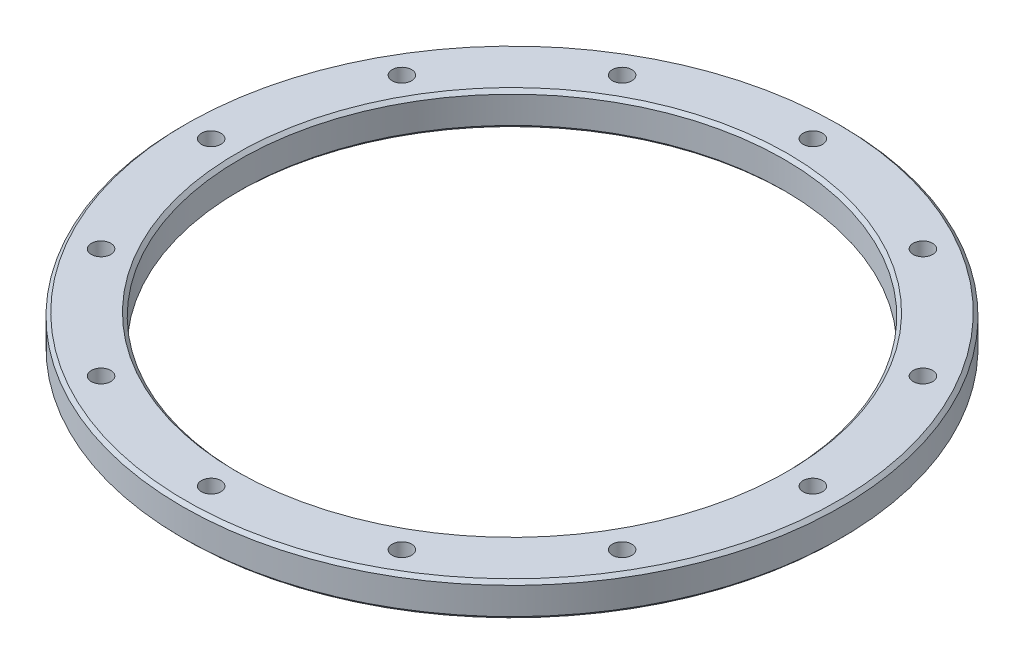
from build123d import *

# Parameters (mm, degrees)
SKETCH1_R           = 61.9125
SKETCH1_R_2         = 51.1175
BOSS_EXTRUDE1_DEPTH = 6.35
CHAMFER1_SIZE       = 0.635
CHAMFER2_SIZE       = 0.635
HOLE1_D             = 3.66
CIRPATTERN1_COUNT   = 12
CHAMFER3_SIZE       = 0.635
CHAMFER4_SIZE       = 0.635


with BuildPart() as part:
    # Sketch1 → Boss-Extrude1 (new body)
    with BuildSketch(Plane(origin=(0, 6.35, 0), x_dir=(1, 0, 0), z_dir=(0, 1, 0))):
        Circle(SKETCH1_R)
        Circle(SKETCH1_R_2, mode=Mode.SUBTRACT)
    extrude(amount=-BOSS_EXTRUDE1_DEPTH)

    # Chamfer1
    chamfer1_edges = [part.edges().sort_by_distance(p)[0] for p in [
        (-51.1175, 0, 0),
    ]]
    chamfer(chamfer1_edges, length=CHAMFER1_SIZE)

    # Chamfer2
    chamfer2_edges = [part.edges().sort_by_distance(p)[0] for p in [
        (-51.1175, 6.35, 0),
    ]]
    chamfer(chamfer2_edges, length=CHAMFER2_SIZE)

    # Hole1 (through all)
    with Locations(Plane(origin=(0, 0, 0), x_dir=(-1, 0, 0), z_dir=(0, -1, 0))):
        with Locations((28.2575, -48.943425695)):
            hole1 = Hole(HOLE1_D / 2)

    # CirPattern1: Hole1 ×12 about axis
    cirpattern1_axis = Axis((0, -96.825, 0), (0, 1, 0))
    for i in range(1, CIRPATTERN1_COUNT):
        add(hole1.rotate(cirpattern1_axis, i * 360 / CIRPATTERN1_COUNT), mode=Mode.SUBTRACT)

    # Chamfer3
    chamfer3_edges = [part.edges().sort_by_distance(p)[0] for p in [
        (-61.9125, 0, 0),
    ]]
    chamfer(chamfer3_edges, length=CHAMFER3_SIZE)

    # Chamfer4
    chamfer4_edges = [part.edges().sort_by_distance(p)[0] for p in [
        (-61.9125, 6.35, 0),
    ]]
    chamfer(chamfer4_edges, length=CHAMFER4_SIZE)


solid = part.part
